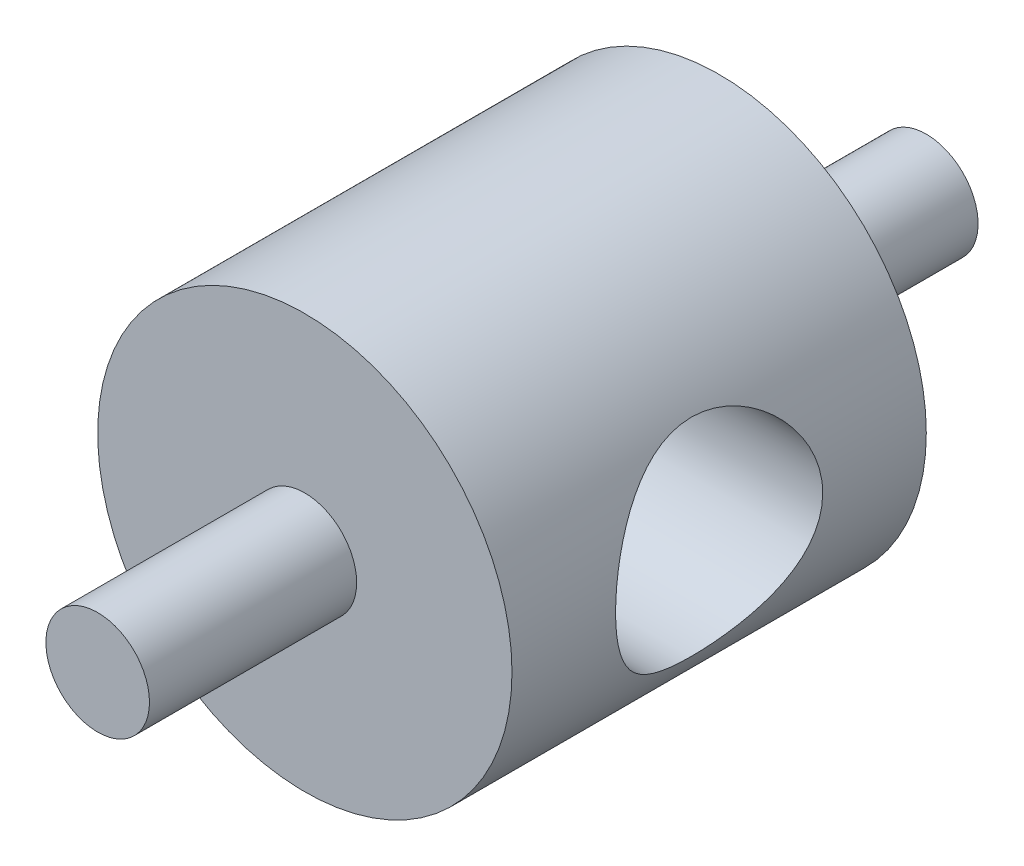
from build123d import *

# Parameters (mm, degrees)
SKETCH1_R                      = 6.35
EXTRUDE1_DEPTH                 = 6.35
EXTRUDE1_DEPTH_BACK            = 6.35
CUT_EXTRUDE1_REACH             = 8.35
SKETCH2_R                      = 3.175
CUT_EXTRUDE1_DIRECTION_2_REACH = 8.35
SKETCH3_R                      = 1.5875
EXTRUDE2_DEPTH                 = 6.35
EXTRUDE2_DEPTH_BACK            = 3.175
SKETCH4_R                      = 1.5875
EXTRUDE3_DEPTH                 = 6.35
EXTRUDE3_DEPTH_BACK            = 3.175


with BuildPart() as part:
    # Sketch1 → Extrude1 (new body, two sides)
    with BuildSketch(Plane.XY) as extrude1_sk:
        Circle(SKETCH1_R)
    extrude(amount=EXTRUDE1_DEPTH)
    extrude(extrude1_sk.sketch, amount=-EXTRUDE1_DEPTH_BACK)

    # Sketch2 → Cut-Extrude1 (cut, up to next)
    with BuildSketch(Plane(origin=(0, 0, 0), x_dir=(0, 0, -1), z_dir=(1, 0, 0)), mode=Mode.PRIVATE) as cut_extrude1_sk1:
        Circle(SKETCH2_R)
    cut_extrude1_tool1 = extrude(cut_extrude1_sk1.sketch, amount=-CUT_EXTRUDE1_REACH, mode=Mode.PRIVATE) & part.part
    add(cut_extrude1_tool1.solids().sort_by_distance((0, 0, 0))[0], mode=Mode.SUBTRACT)

    # Sketch2 → Cut-Extrude1 direction 2 (cut, up to next)
    with BuildSketch(Plane(origin=(0, 0, 0), x_dir=(0, 0, -1), z_dir=(1, 0, 0)), mode=Mode.PRIVATE) as cut_extrude1_direction_2_sk1:
        Circle(SKETCH2_R)
    cut_extrude1_direction_2_tool1 = extrude(cut_extrude1_direction_2_sk1.sketch, amount=CUT_EXTRUDE1_DIRECTION_2_REACH, mode=Mode.PRIVATE) & part.part
    add(cut_extrude1_direction_2_tool1.solids().sort_by_distance((0, 0, 0))[0], mode=Mode.SUBTRACT)


with BuildPart() as body_2:
    # Sketch3 → Extrude2 (new body, two sides)
    with BuildSketch(Plane.XY.offset(6.35)) as extrude2_sk:
        Circle(SKETCH3_R)
    extrude(amount=EXTRUDE2_DEPTH)
    extrude(extrude2_sk.sketch, amount=-EXTRUDE2_DEPTH_BACK)


with BuildPart() as body_3:
    # Sketch4 → Extrude3 (new body, two sides)
    with BuildSketch(Plane(origin=(0, 0, -6.35), x_dir=(-1, 0, 0), z_dir=(0, 0, -1))) as extrude3_sk:
        Circle(SKETCH4_R)
    extrude(amount=EXTRUDE3_DEPTH)
    extrude(extrude3_sk.sketch, amount=-EXTRUDE3_DEPTH_BACK)


solid = Compound([part.part, body_2.part, body_3.part])
